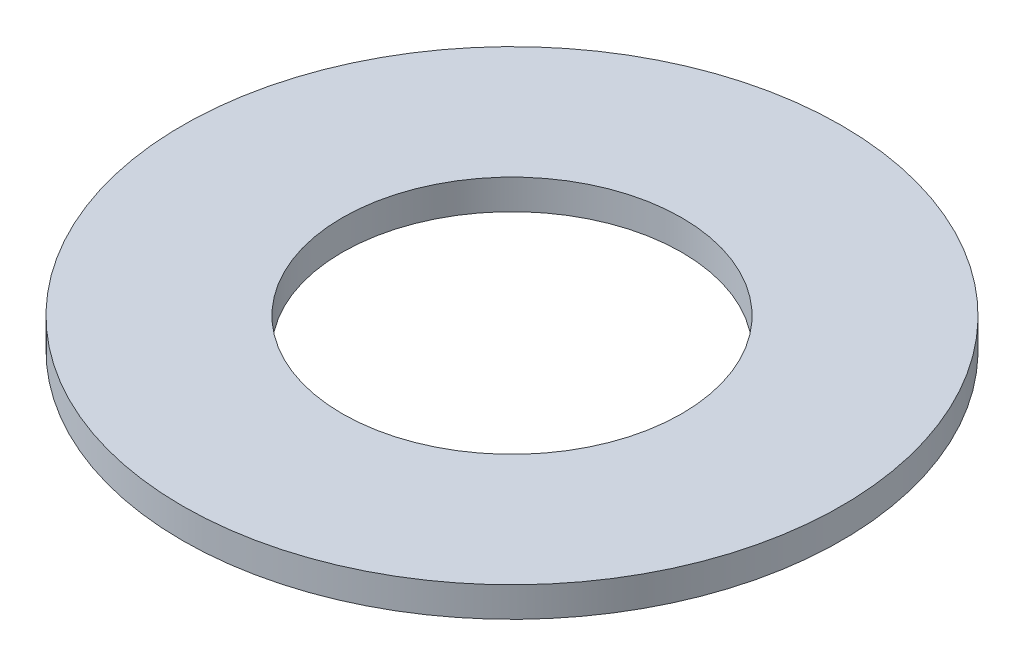
from build123d import *

# Parameters (mm, degrees)
SKETCH_1_W = 8
SKETCH_1_H = 1.5


with BuildPart() as part:
    # Эскиз1 → Повернуть1 (revolve)
    with BuildSketch(Plane(origin=(0, 0, 0), x_dir=(0, 0, -1), z_dir=(1, 0, 0))):
        with Locations((12.5, 0.75)):
            Rectangle(SKETCH_1_W, SKETCH_1_H)
    revolve(axis=Axis((0, 0, 0), (0, 1, 0)))


solid = part.part
